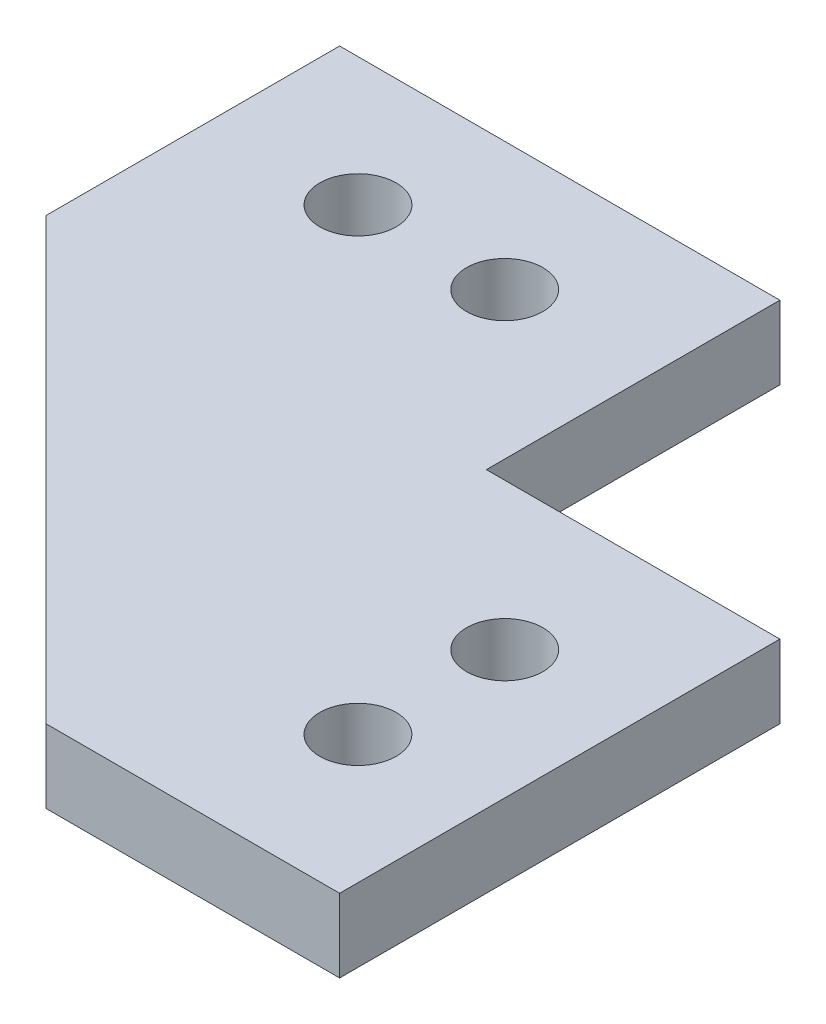
from build123d import *

# Parameters (mm, degrees)
SKETCH1_R           = 1.651
BOSS_EXTRUDE1_DEPTH = 3.175


with BuildPart() as part:
    # Sketch1 → Boss-Extrude1 (new body)
    with BuildSketch(Plane(origin=(0, 0, 0), x_dir=(1, 0, 0), z_dir=(0, 1, 0))):
        Polygon((38.1, -12.7), (25.4, -12.7), (25.4, 0), (6.35, 0), (6.35, -12.7), (25.4, -31.75), (38.1, -31.75), align=None)
        with Locations((32.54375, -19.05)):
            Circle(SKETCH1_R, mode=Mode.SUBTRACT)
        with Locations((32.54375, -25.4)):
            Circle(SKETCH1_R, mode=Mode.SUBTRACT)
        with Locations((12.7, -5.55625)):
            Circle(SKETCH1_R, mode=Mode.SUBTRACT)
        with Locations((19.05, -5.55625)):
            Circle(SKETCH1_R, mode=Mode.SUBTRACT)
    extrude(amount=BOSS_EXTRUDE1_DEPTH)


solid = part.part
